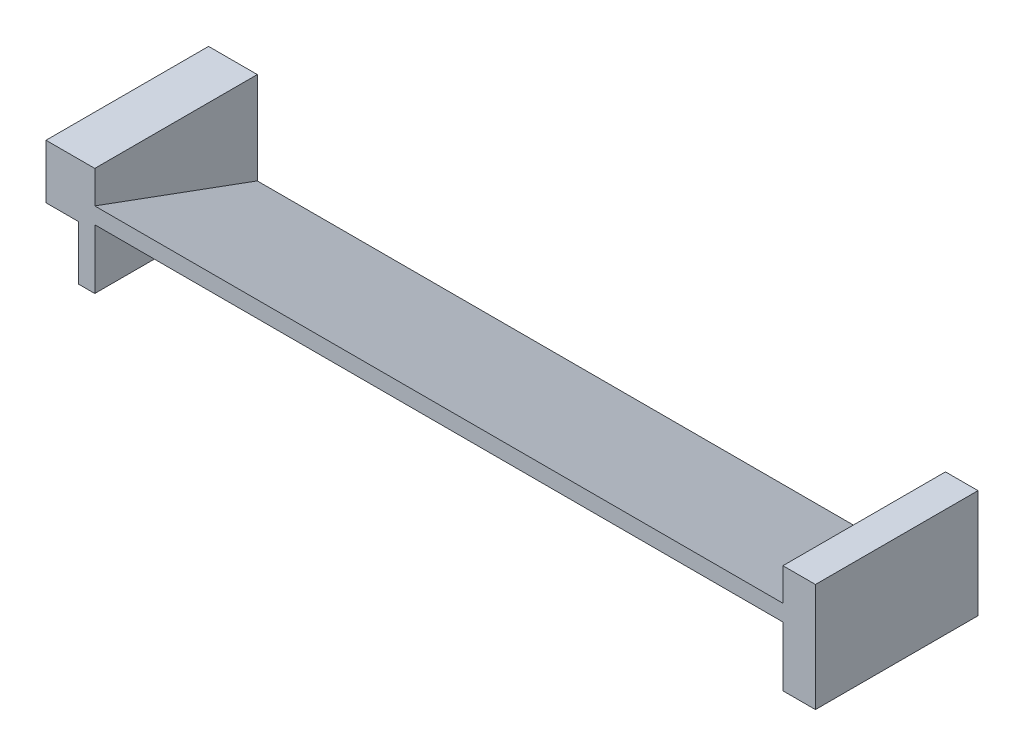
from build123d import *

# Parameters (mm, degrees)
SKETCH_5_W        = 6
SKETCH_5_H        = 30
EXTRUDE_2_DEPTH   = 10
EXTRUDE_2_2_DEPTH = 10
SKETCH_6_W        = 6
SKETCH_6_H        = 30
EXTRUDE_3_DEPTH   = 10
EXTRUDE_4_DEPTH   = 3
EXTRUDE_5_DEPTH   = 127


with BuildPart() as part:
    # 스케치5 → 보스-돌출2 (new body)
    with BuildSketch(Plane(origin=(0, 0, 0), x_dir=(1, 0, 0), z_dir=(0, 1, 0))):
        with Locations((68, 0)):
            Rectangle(SKETCH_5_W, SKETCH_5_H)
    extrude(amount=-EXTRUDE_2_DEPTH)

    # 스케치6 → 보스-돌출3 (add)
    with BuildSketch(Plane.XZ.offset(10)):
        with Locations((68, 0)):
            Rectangle(SKETCH_6_W, SKETCH_6_H)
    extrude(amount=EXTRUDE_3_DEPTH)



with BuildPart() as body_2:
    # 스케치5 → Extrude 2 2 (new body)
    with BuildSketch(Plane(origin=(0, 0, 0), x_dir=(1, 0, 0), z_dir=(0, 1, 0))):
        with Locations((-68, 0)):
            Rectangle(SKETCH_5_W, SKETCH_5_H)
    extrude(amount=-EXTRUDE_2_2_DEPTH)

    # 스케치8 → 보스-돌출4 (add)
    with BuildSketch(Plane(origin=(-65, 0, 0), x_dir=(0, 0, -1), z_dir=(1, 0, 0))):
        Polygon((15, -14), (15, -20), (-15, -20), (-15, 0), (15, 0), align=None)
    extrude(amount=EXTRUDE_4_DEPTH)


with BuildPart() as part_1:
    add(part.part)

    add(body_2.part)  # 보스-돌출5 merges body 2
    # 스케치7 → 보스-돌출5 (add)
    with BuildSketch(Plane.ZY.offset(-65)):
        Polygon((-15, -17), (-15, -20), (15, -9), (15, -6), align=None)
    extrude(amount=EXTRUDE_5_DEPTH)


solid = part_1.part
